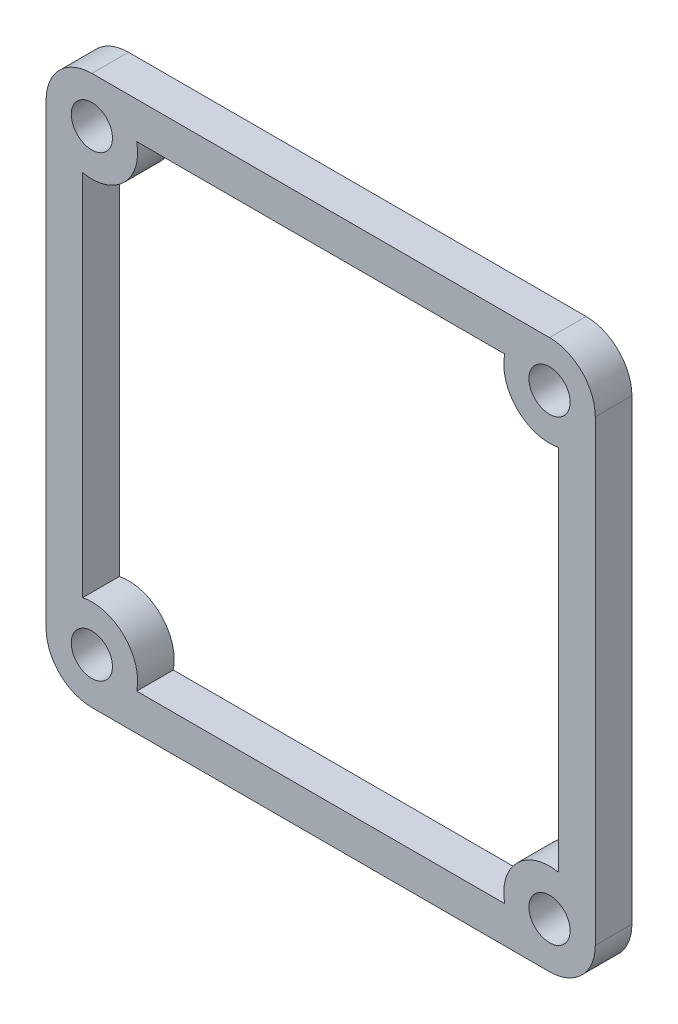
from build123d import *

# Parameters (mm, degrees)
SKETCH1_W           = 60
SKETCH1_H           = 60
BOSS_EXTRUDE1_DEPTH = 4
SKETCH2_R           = 2.25
CUT_EXTRUDE1_DEPTH  = 4
CUT_EXTRUDE2_DEPTH  = 4


with BuildPart() as part:
    # Sketch1 → Boss-Extrude1 (new body)
    with BuildSketch(Plane.XY):
        Rectangle(SKETCH1_W, SKETCH1_H)
    extrude(amount=BOSS_EXTRUDE1_DEPTH)

    # Sketch2 → Cut-Extrude1 (cut)
    with BuildSketch(Plane.XY.offset(4)):
        with Locations((-25, 25)):
            Circle(SKETCH2_R)
        with Locations((25, 25)):
            Circle(SKETCH2_R)
        with Locations((25, -25)):
            Circle(SKETCH2_R)
        with Locations((-25, -25)):
            Circle(SKETCH2_R)
    extrude(amount=-CUT_EXTRUDE1_DEPTH, mode=Mode.SUBTRACT)

    # Sketch3 → Cut-Extrude2 (cut)
    with BuildSketch(Plane.XY.offset(4)):
        with BuildLine():
            Line((-25, 30), (-30, 30))
            Line((-30, 30), (-30, 25))
            ThreePointArc((-30, 25), (-28.535533906, 28.535533906), (-25, 30))
        make_face()
        with BuildLine():
            ThreePointArc((20.101020514, 26), (21.464466094, 21.464466094), (26, 20.101020514))
            Line((26, 20.101020514), (26, -20.101020514))
            ThreePointArc((26, -20.101020514), (21.464466094, -21.464466094), (20.101020514, -26))
            Line((20.101020514, -26), (-20.101020514, -26))
            ThreePointArc((-20.101020514, -26), (-21.464466094, -21.464466094), (-26, -20.101020514))
            Line((-26, -20.101020514), (-26, 20.101020514))
            ThreePointArc((-26, 20.101020514), (-21.464466094, 21.464466094), (-20.101020514, 26))
            Line((-20.101020514, 26), (20.101020514, 26))
        make_face()
        with BuildLine():
            Line((30, 30), (25, 30))
            ThreePointArc((25, 30), (28.535533906, 28.535533906), (30, 25))
            Line((30, 25), (30, 30))
        make_face()
        with BuildLine():
            ThreePointArc((30, -25), (28.535533906, -28.535533906), (25, -30))
            Line((25, -30), (30, -30))
            Line((30, -30), (30, -25))
        make_face()
        with BuildLine():
            ThreePointArc((-25, -30), (-28.535533906, -28.535533906), (-30, -25))
            Line((-30, -25), (-30, -30))
            Line((-30, -30), (-25, -30))
        make_face()
    extrude(amount=-CUT_EXTRUDE2_DEPTH, mode=Mode.SUBTRACT)


solid = part.part
